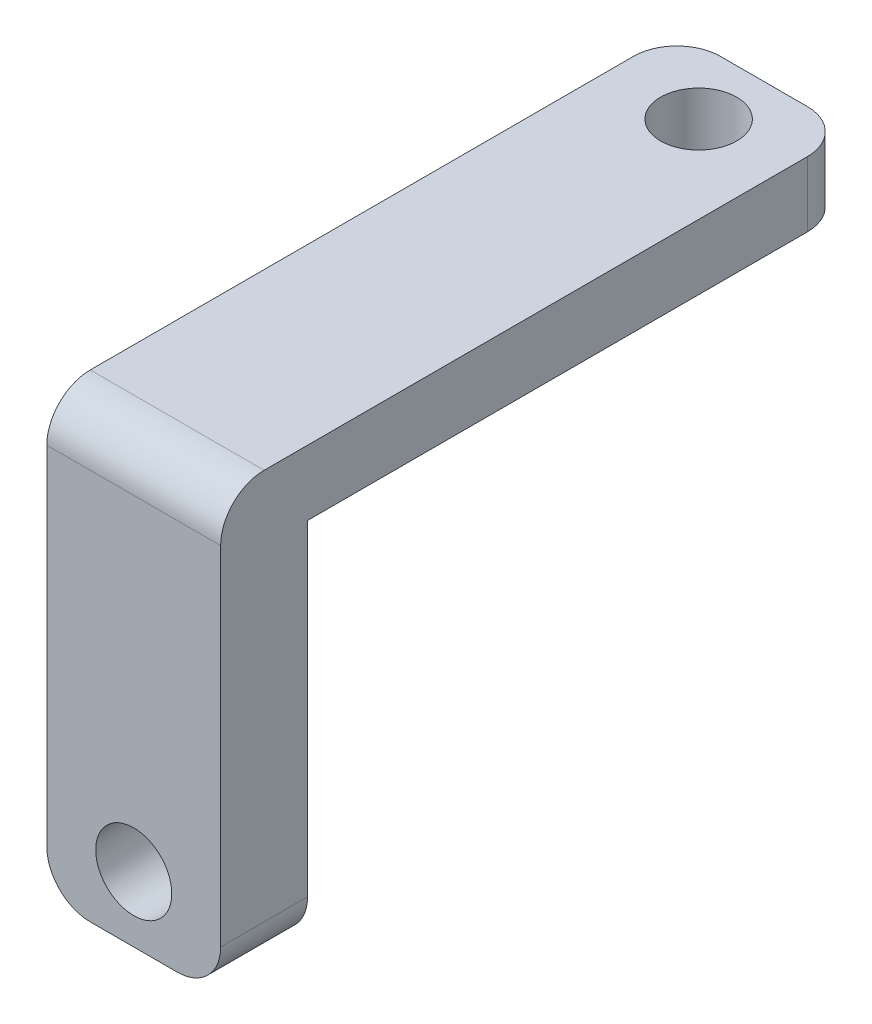
from build123d import *

# Parameters (mm, degrees)
ESQUISSE1_W        = 8
ESQUISSE1_H        = 25
ESQUISSE1_R        = 1.75
BOSS_EXTRU_1_DEPTH = 3
ESQUISSE2_W        = 8
ESQUISSE2_H        = 20
ESQUISSE2_R        = 1.75
BOSS_EXTRU_2_DEPTH = 4
CONG_1_R           = 2


with BuildPart() as part:
    # Esquisse1 → Boss.-Extru.1 (new body)
    with BuildSketch(Plane(origin=(0, 0, 0), x_dir=(1, 0, 0), z_dir=(0, 1, 0))):
        Rectangle(ESQUISSE1_W, ESQUISSE1_H)
        with Locations((0, 9.5)):
            Circle(ESQUISSE1_R, mode=Mode.SUBTRACT)
    extrude(amount=BOSS_EXTRU_1_DEPTH)

    # Esquisse2 → Boss.-Extru.2 (add)
    with BuildSketch(Plane.XY.offset(12.5)):
        with Locations((0, -7)):
            Rectangle(ESQUISSE2_W, ESQUISSE2_H)
        with Locations((0, -14)):
            Circle(ESQUISSE2_R, mode=Mode.SUBTRACT)
    extrude(amount=BOSS_EXTRU_2_DEPTH)

    # Congé1
    cong_1_edges = [part.edges().sort_by_distance(p)[0] for p in [
        (0, 3, 16.5),
        (-4, -17, 14.5),
        (4, -17, 14.5),
        (-4, 1.5, -12.5),
        (4, 1.5, -12.5),
    ]]
    fillet(cong_1_edges, radius=CONG_1_R)


solid = part.part
